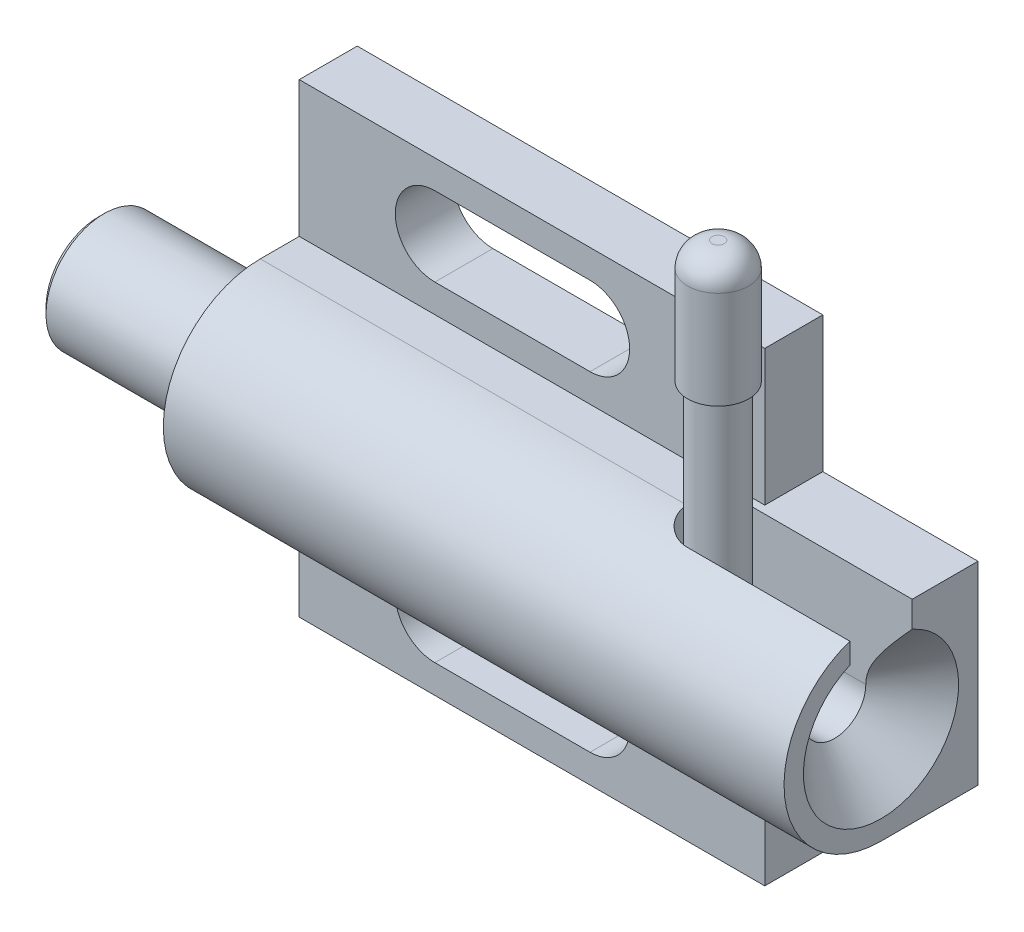
from build123d import *

# Parameters (mm, degrees)
BOSS_EXTRUDE2_DEPTH = 50.8
SKETCH5_W           = 4.7498
SKETCH5_H           = 11.1125
CUT_EXTRUDE3_DEPTH  = 12.7
CUT_REVOLVE2_ANGLE  = 360
CUT_EXTRUDE4_REACH  = 21.05
CUT_EXTRUDE5_REACH  = 17.875
REVOLVE1_ANGLE      = 360
REVOLVE2_ANGLE      = 360
SKETCH12_R          = 2


with BuildPart() as part:
    # Sketch4 → Boss-Extrude2 (new body)
    with BuildSketch(Plane(origin=(25.4, 0, 0), x_dir=(0, 0, -1), z_dir=(1, 0, 0))):
        with BuildLine():
            Line((0, -19.05), (0, 19.05))
            Line((0, 19.05), (-4.7498, 19.05))
            Line((-4.7498, 19.05), (-4.7498, 7.9375))
            Line((-4.7498, 7.9375), (-7.9375, 7.9375))
            ThreePointArc((-7.9375, 7.9375), (-15.875, 0), (-7.9375, -7.9375))
            Line((-7.9375, -7.9375), (-4.7498, -7.9375))
            Line((-4.7498, -7.9375), (-4.7498, -19.05))
            Line((-4.7498, -19.05), (0, -19.05))
        make_face()
    extrude(amount=BOSS_EXTRUDE2_DEPTH)

    # Sketch5 → Cut-Extrude3 (cut)
    with BuildSketch(Plane(origin=(76.2, 0, 0), x_dir=(0, 0, -1), z_dir=(1, 0, 0))):
        with Locations((-2.3749, 13.49375)):
            Rectangle(SKETCH5_W, SKETCH5_H)
        with Locations((-2.3749, -13.49375)):
            Rectangle(SKETCH5_W, SKETCH5_H)
    extrude(amount=-CUT_EXTRUDE3_DEPTH, mode=Mode.SUBTRACT)

    # Sketch6 → Cut-Revolve2 (revolve, symmetric, cut)
    with BuildSketch(Plane(origin=(0, 0, 0), x_dir=(1, 0, 0), z_dir=(0, 1, 0))) as cut_revolve2_sk:
        Polygon((25.4, -7.9375), (25.4, -13.8397), (26.4, -12.8397), (57.15, -12.8397), (58.561722024, -10.4902), (72.4027, -10.4902), (76.2, -14.2875), (76.2, -7.9375), align=None)
    revolve(axis=Axis((25.4, 0, 7.9375), (1, 0, 0)), revolution_arc=CUT_REVOLVE2_ANGLE / 2, mode=Mode.SUBTRACT)
    revolve(cut_revolve2_sk.sketch, axis=Axis((25.4, 0, 7.9375), (-1, 0, 0)), revolution_arc=CUT_REVOLVE2_ANGLE / 2, mode=Mode.SUBTRACT)

    # Sketch7 → Cut-Extrude4 (cut, up to next)
    with BuildSketch(Plane(origin=(0, 0, 0), x_dir=(1, 0, 0), z_dir=(0, 1, 0)), mode=Mode.PRIVATE) as cut_extrude4_sk1:
        with BuildLine():
            Line((62.87516, -10.4902), (76.2, -10.4902))
            Line((76.2, -10.4902), (76.2, -5.3848))
            Line((76.2, -5.3848), (62.87516, -5.3848))
            ThreePointArc((62.87516, -5.3848), (60.32246, -7.9375), (62.87516, -10.4902))
        make_face()
    cut_extrude4_tool1 = extrude(cut_extrude4_sk1.sketch, amount=CUT_EXTRUDE4_REACH, mode=Mode.PRIVATE) & part.part
    add(cut_extrude4_tool1.solids().sort_by_distance((68.524549, 0, 7.9375))[0], mode=Mode.SUBTRACT)

    # Sketch8 → Cut-Extrude5 (cut, up to next)
    with BuildSketch(Plane.XY, mode=Mode.PRIVATE) as cut_extrude5_sk1:
        with BuildLine():
            Line((36.4998, 16.7259), (49.1998, 16.7259))
            ThreePointArc((49.1998, 16.7259), (52.4383, 13.4874), (49.1998, 10.2489))
            Line((49.1998, 10.2489), (36.4998, 10.2489))
            ThreePointArc((36.4998, 10.2489), (33.2613, 13.4874), (36.4998, 16.7259))
        make_face()
    cut_extrude5_tool1 = extrude(cut_extrude5_sk1.sketch, amount=CUT_EXTRUDE5_REACH, mode=Mode.PRIVATE) & part.part
    add(cut_extrude5_tool1.solids().sort_by_distance((42.8498, 13.4874, 0))[0], mode=Mode.SUBTRACT)
    # Sketch8 → Cut-Extrude5 (cut, up to next)
    with BuildSketch(Plane.XY, mode=Mode.PRIVATE) as cut_extrude5_sk2:
        with BuildLine():
            Line((36.4998, -16.7259), (49.1998, -16.7259))
            ThreePointArc((49.1998, -16.7259), (52.4383, -13.4874), (49.1998, -10.2489))
            Line((49.1998, -10.2489), (36.4998, -10.2489))
            ThreePointArc((36.4998, -10.2489), (33.2613, -13.4874), (36.4998, -16.7259))
        make_face()
    cut_extrude5_tool2 = extrude(cut_extrude5_sk2.sketch, amount=CUT_EXTRUDE5_REACH, mode=Mode.PRIVATE) & part.part
    add(cut_extrude5_tool2.solids().sort_by_distance((42.8498, -13.4874, 0))[0], mode=Mode.SUBTRACT)


with BuildPart() as body_2:
    # Sketch9 → Revolve1 (revolve, symmetric)
    with BuildSketch(Plane.XY.offset(7.9375)) as revolve1_sk:
        Polygon((12.12516, 0), (12.12516, 4.2625), (12.62516, 4.7625), (41.62516, 4.7625), (41.62516, 2), (60.37516, 2), (60.37516, 0), align=None)
    revolve(axis=Axis((12.12516, 0, 7.9375), (1, 0, 0)), revolution_arc=REVOLVE1_ANGLE / 2)
    revolve(revolve1_sk.sketch, axis=Axis((12.12516, 0, 7.9375), (-1, 0, 0)), revolution_arc=REVOLVE1_ANGLE / 2)



with BuildPart() as body_3:
    # Sketch11 → Revolve2 (revolve, symmetric)
    with BuildSketch(Plane.XY.offset(7.9375)) as revolve2_sk:
        with BuildLine():
            Line((60.87516, 2.5), (60.87516, 18))
            Line((60.87516, 18), (60.37516, 18))
            Line((60.37516, 18), (60.37516, 26))
            ThreePointArc((60.37516, 26), (60.960946438, 27.414213562), (62.37516, 28))
            Line((62.37516, 28), (62.87516, 28))
            Line((62.87516, 28), (62.87516, 2.5))
            Line((62.87516, 2.5), (60.87516, 2.5))
        make_face()
    revolve(axis=Axis((62.87516, 2.5, 7.9375), (0, 1, 0)), revolution_arc=REVOLVE2_ANGLE / 2)
    revolve(revolve2_sk.sketch, axis=Axis((62.87516, 2.5, 7.9375), (0, -1, 0)), revolution_arc=REVOLVE2_ANGLE / 2)


with BuildPart() as body_2_1:
    add(body_2.part)

    add(body_3.part)  # Sweep1 merges body 3
    # Sweep1: sweep along a path in Sketch13
    with BuildLine(Plane.XY.offset(7.9375)) as sweep1_path:
        ThreePointArc((60.37516, 0), (62.142926953, 0.732233047), (62.87516, 2.5))
    # Sketch12 → Sweep1 (sweep)
    with BuildSketch(Plane(origin=(60.37516, 0, 0), x_dir=(0, 0, -1), z_dir=(1, 0, 0))):
        with Locations((-7.9375, 0)):
            Circle(SKETCH12_R)
    sweep(path=sweep1_path.line)


solid = Compound([part.part, body_2_1.part])
